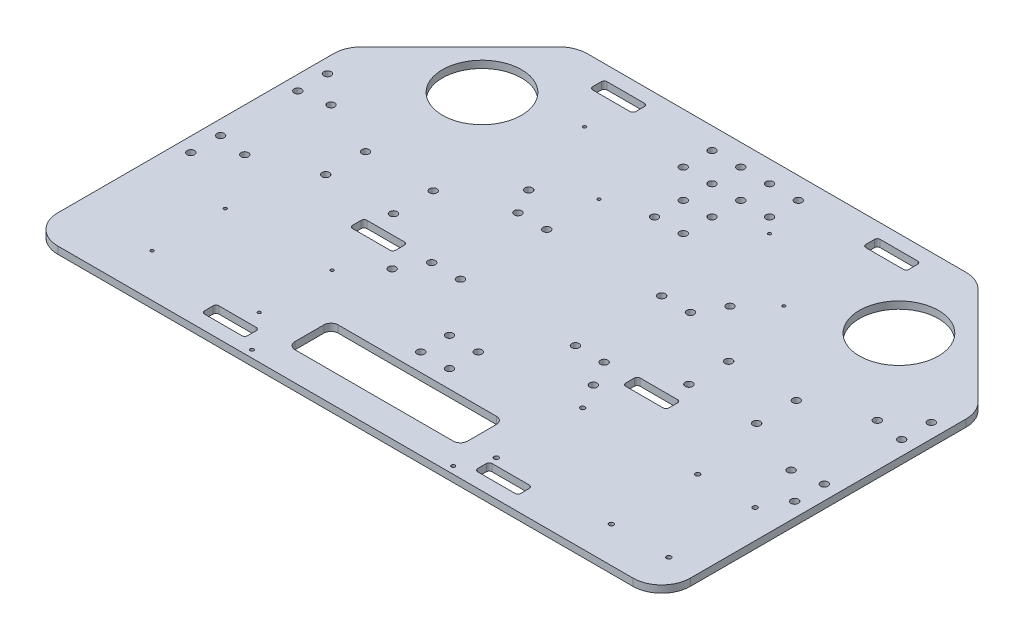
from build123d import *

# Parameters (mm, degrees)
SKETCH1_W          = 558.8
SKETCH1_H          = 381
EXTRUDE1_DEPTH     = 6.35
SKETCH2_R          = 3.2639
CUT_EXTRUDE1_DEPTH = 7.35
CUT_EXTRUDE2_REACH = 8.35
SKETCH4_R          = 3.2639
CUT_EXTRUDE3_DEPTH = 7.35
SKETCH5_R          = 3.2639
CUT_EXTRUDE4_DEPTH = 7.35
SKETCH6_R          = 2.0193
SKETCH6_R_2        = 1.3589
CUT_EXTRUDE5_DEPTH = 7.35
SKETCH7_R          = 3.2639
SKETCH7_R_2        = 1.57988
CUT_EXTRUDE6_DEPTH = 7.35
CUT_EXTRUDE7_DEPTH = 7.35
CHAMFER1_SIZE      = 101.6
FILLET1_R          = 25.4
SKETCH9_R          = 34.925
CUT_EXTRUDE8_DEPTH = 7.35
SKETCH10_R         = 3.2639
CUT_EXTRUDE9_DEPTH = 7.35


with BuildPart() as part:
    # Sketch1 → Extrude1 (new body)
    with BuildSketch(Plane(origin=(0, 0, 0), x_dir=(1, 0, 0), z_dir=(0, 1, 0))):
        Rectangle(SKETCH1_W, SKETCH1_H)
    extrude(amount=EXTRUDE1_DEPTH)

    # Sketch2 → Cut-Extrude1 (cut, through all)
    with BuildSketch(Plane(origin=(0, 6.35, 0), x_dir=(-1, 0, 0), z_dir=(0, 1, 0))):
        with Locations((-130.4671, 17.5641)):
            Circle(SKETCH2_R)
        with Locations((-130.4671, -17.5641)):
            Circle(SKETCH2_R)
        with Locations((130.4671, 17.5641)):
            Circle(SKETCH2_R)
        with Locations((130.4671, -17.5641)):
            Circle(SKETCH2_R)
        with Locations((-190.3095, 17.5641)):
            Circle(SKETCH2_R)
        with Locations((-190.3095, -17.5641)):
            Circle(SKETCH2_R)
        with Locations((190.3095, -17.5641)):
            Circle(SKETCH2_R)
        with Locations((190.3095, 17.5641)):
            Circle(SKETCH2_R)
    extrude(amount=-CUT_EXTRUDE1_DEPTH, mode=Mode.SUBTRACT)

    # Sketch3 → Cut-Extrude2 (cut, up to next)
    with BuildSketch(Plane(origin=(0, 6.35, 0), x_dir=(-1, 0, 0), z_dir=(0, 1, 0)), mode=Mode.PRIVATE) as cut_extrude2_sk1:
        with BuildLine():
            Line((-69.85, 165.1), (69.85, 165.1))
            ThreePointArc((69.85, 165.1), (74.340128061, 163.240128061), (76.2, 158.75))
            Line((76.2, 158.75), (76.2, 133.35))
            ThreePointArc((76.2, 133.35), (74.340128061, 128.859871939), (69.85, 127))
            Line((69.85, 127), (-69.85, 127))
            ThreePointArc((-69.85, 127), (-74.340128061, 128.859871939), (-76.2, 133.35))
            Line((-76.2, 133.35), (-76.2, 158.75))
            ThreePointArc((-76.2, 158.75), (-74.340128061, 163.240128061), (-69.85, 165.1))
        make_face()
    cut_extrude2_tool1 = extrude(cut_extrude2_sk1.sketch, amount=-CUT_EXTRUDE2_REACH, mode=Mode.PRIVATE) & part.part
    add(cut_extrude2_tool1.solids().sort_by_distance((0, 6.35, 146.05))[0], mode=Mode.SUBTRACT)

    # Sketch4 → Cut-Extrude3 (cut, through all)
    with BuildSketch(Plane(origin=(0, 6.35, 0), x_dir=(-1, 0, 0), z_dir=(0, 1, 0))):
        with Locations((-266.6492, 34.13125)):
            Circle(SKETCH4_R)
        with Locations((-266.6492, -34.13125)):
            Circle(SKETCH4_R)
        with Locations((266.6492, -34.13125)):
            Circle(SKETCH4_R)
        with Locations((266.6492, 34.13125)):
            Circle(SKETCH4_R)
    extrude(amount=-CUT_EXTRUDE3_DEPTH, mode=Mode.SUBTRACT)

    # Sketch5 → Cut-Extrude4 (cut, through all)
    with BuildSketch(Plane.XZ):
        with Locations((-266.7, 60.325)):
            Circle(SKETCH5_R)
        with Locations((-88.9, 60.325)):
            Circle(SKETCH5_R)
        with Locations((-88.9, -60.325)):
            Circle(SKETCH5_R)
        with Locations((-266.7, -60.325)):
            Circle(SKETCH5_R)
        with Locations((266.7, -60.325)):
            Circle(SKETCH5_R)
        with Locations((88.9, -60.325)):
            Circle(SKETCH5_R)
        with Locations((88.9, 60.325)):
            Circle(SKETCH5_R)
        with Locations((266.7, 60.325)):
            Circle(SKETCH5_R)
    extrude(amount=-CUT_EXTRUDE4_DEPTH, mode=Mode.SUBTRACT)

    # Sketch6 → Cut-Extrude5 (cut, through all)
    with BuildSketch(Plane(origin=(0, 6.35, 0), x_dir=(-1, 0, 0), z_dir=(0, 1, 0))):
        with Locations((-254, 158.75)):
            Circle(SKETCH6_R)
        with Locations((-203.2, 158.75)):
            Circle(SKETCH6_R)
        with Locations((-101.6, 158.75)):
            Circle(SKETCH6_R)
        with Locations((-254, 82.55)):
            Circle(SKETCH6_R)
        with Locations((-203.2, 82.55)):
            Circle(SKETCH6_R)
        with Locations((-101.6, 82.55)):
            Circle(SKETCH6_R)
        with Locations((114.3, 152.4)):
            Circle(SKETCH6_R_2)
        with Locations((208.788, 152.4)):
            Circle(SKETCH6_R_2)
        with Locations((114.3, 87.9094)):
            Circle(SKETCH6_R_2)
        with Locations((208.788, 87.9094)):
            Circle(SKETCH6_R_2)
        with Locations((-112.522, -84.328)):
            Circle(SKETCH6_R_2)
        with Locations((-50.8, -133.35)):
            Circle(SKETCH6_R_2)
        with Locations((112.522, -133.35)):
            Circle(SKETCH6_R_2)
        with Locations((50.8, -84.328)):
            Circle(SKETCH6_R_2)
    extrude(amount=-CUT_EXTRUDE5_DEPTH, mode=Mode.SUBTRACT)

    # Sketch7 → Cut-Extrude6 (cut, through all)
    with BuildSketch(Plane(origin=(0, 6.35, 0), x_dir=(-1, 0, 0), z_dir=(0, 1, 0))):
        with Locations((-12.7, -171.45)):
            Circle(SKETCH7_R)
        with Locations((12.7, -171.45)):
            Circle(SKETCH7_R)
        with Locations((-12.7, -120.65)):
            Circle(SKETCH7_R)
        with Locations((12.7, -120.65)):
            Circle(SKETCH7_R)
        with Locations((-88.9, 184.15)):
            Circle(SKETCH7_R_2)
        with Locations((88.9, 184.15)):
            Circle(SKETCH7_R_2)
        with Locations((12.7, -146.05)):
            Circle(SKETCH7_R)
        with Locations((-12.7, -146.05)):
            Circle(SKETCH7_R)
        with Locations((38.1, -146.05)):
            Circle(SKETCH7_R)
        with Locations((38.1, -171.45)):
            Circle(SKETCH7_R)
        with Locations((-38.1, -171.45)):
            Circle(SKETCH7_R)
        with Locations((-38.1, -146.05)):
            Circle(SKETCH7_R)
        with Locations((12.7, 85.852)):
            Circle(SKETCH7_R)
        with Locations((-12.7, 85.852)):
            Circle(SKETCH7_R)
        with Locations((12.7, -95.25)):
            Circle(SKETCH7_R)
        with Locations((-12.7, -95.25)):
            Circle(SKETCH7_R)
        with Locations((12.7, 111.252)):
            Circle(SKETCH7_R)
        with Locations((-12.7, 111.252)):
            Circle(SKETCH7_R)
    extrude(amount=-CUT_EXTRUDE6_DEPTH, mode=Mode.SUBTRACT)

    # Sketch8 → Cut-Extrude7 (cut, through all)
    with BuildSketch(Plane.XZ):
        with BuildLine():
            Line((-137.16, 177.8), (-104.14, 177.8))
            ThreePointArc((-104.14, 177.8), (-102.343948776, 177.056051224), (-101.6, 175.26))
            Line((-101.6, 175.26), (-101.6, 167.64))
            ThreePointArc((-101.6, 167.64), (-102.343948776, 165.843948776), (-104.14, 165.1))
            Line((-104.14, 165.1), (-137.16, 165.1))
            ThreePointArc((-137.16, 165.1), (-138.956051224, 165.843948776), (-139.7, 167.64))
            Line((-139.7, 167.64), (-139.7, 175.26))
            ThreePointArc((-139.7, 175.26), (-138.956051224, 177.056051224), (-137.16, 177.8))
        make_face()
        with BuildLine():
            Line((-101.6, -175.26), (-101.6, -167.64))
            ThreePointArc((-101.6, -167.64), (-102.343948776, -165.843948776), (-104.14, -165.1))
            Line((-104.14, -165.1), (-137.16, -165.1))
            ThreePointArc((-137.16, -165.1), (-138.956051224, -165.843948776), (-139.7, -167.64))
            Line((-139.7, -167.64), (-139.7, -175.26))
            ThreePointArc((-139.7, -175.26), (-138.956051224, -177.056051224), (-137.16, -177.8))
            Line((-137.16, -177.8), (-104.14, -177.8))
            ThreePointArc((-104.14, -177.8), (-102.343948776, -177.056051224), (-101.6, -175.26))
        make_face()
        with BuildLine():
            Line((137.16, -177.8), (104.14, -177.8))
            ThreePointArc((104.14, -177.8), (102.343948776, -177.056051224), (101.6, -175.26))
            Line((101.6, -175.26), (101.6, -167.64))
            ThreePointArc((101.6, -167.64), (102.343948776, -165.843948776), (104.14, -165.1))
            Line((104.14, -165.1), (137.16, -165.1))
            ThreePointArc((137.16, -165.1), (138.956051224, -165.843948776), (139.7, -167.64))
            Line((139.7, -167.64), (139.7, -175.26))
            ThreePointArc((139.7, -175.26), (138.956051224, -177.056051224), (137.16, -177.8))
        make_face()
        with BuildLine():
            Line((101.6, 175.26), (101.6, 167.64))
            ThreePointArc((101.6, 167.64), (102.343948776, 165.843948776), (104.14, 165.1))
            Line((104.14, 165.1), (137.16, 165.1))
            ThreePointArc((137.16, 165.1), (138.956051224, 165.843948776), (139.7, 167.64))
            Line((139.7, 167.64), (139.7, 175.26))
            ThreePointArc((139.7, 175.26), (138.956051224, 177.056051224), (137.16, 177.8))
            Line((137.16, 177.8), (104.14, 177.8))
            ThreePointArc((104.14, 177.8), (102.343948776, 177.056051224), (101.6, 175.26))
        make_face()
        with BuildLine():
            Line((101.6, 44.45), (101.6, 36.83))
            ThreePointArc((101.6, 36.83), (102.343948776, 35.033948776), (104.14, 34.29))
            Line((104.14, 34.29), (137.16, 34.29))
            ThreePointArc((137.16, 34.29), (138.956051224, 35.033948776), (139.7, 36.83))
            Line((139.7, 36.83), (139.7, 44.45))
            ThreePointArc((139.7, 44.45), (138.956051224, 46.246051224), (137.16, 46.99))
            Line((137.16, 46.99), (104.14, 46.99))
            ThreePointArc((104.14, 46.99), (102.343948776, 46.246051224), (101.6, 44.45))
        make_face()
        with BuildLine():
            Line((-137.16, 46.99), (-104.14, 46.99))
            ThreePointArc((-104.14, 46.99), (-102.343948776, 46.246051224), (-101.6, 44.45))
            Line((-101.6, 44.45), (-101.6, 36.83))
            ThreePointArc((-101.6, 36.83), (-102.343948776, 35.033948776), (-104.14, 34.29))
            Line((-104.14, 34.29), (-137.16, 34.29))
            ThreePointArc((-137.16, 34.29), (-138.956051224, 35.033948776), (-139.7, 36.83))
            Line((-139.7, 36.83), (-139.7, 44.45))
            ThreePointArc((-139.7, 44.45), (-138.956051224, 46.246051224), (-137.16, 46.99))
        make_face()
    extrude(amount=-CUT_EXTRUDE7_DEPTH, mode=Mode.SUBTRACT)

    # Chamfer1
    chamfer1_edges = [part.edges().sort_by_distance(p)[0] for p in [
        (-279.4, 3.175, -190.5),
        (279.4, 3.175, -190.5),
    ]]
    chamfer(chamfer1_edges, length=CHAMFER1_SIZE)

    # Fillet1
    fillet1_edges = [part.edges().sort_by_distance(p)[0] for p in [
        (-177.8, 3.175, -190.5),
        (177.8, 3.175, -190.5),
        (279.4, 3.175, -88.9),
        (-279.4, 3.175, -88.9),
        (279.4, 3.175, 190.5),
        (-279.4, 3.175, 190.5),
    ]]
    fillet(fillet1_edges, radius=FILLET1_R)

    # Sketch9 → Cut-Extrude8 (cut, through all)
    with BuildSketch(Plane(origin=(0, 6.35, 0), x_dir=(-1, 0, 0), z_dir=(0, 1, 0))):
        with Locations((-184.15, -114.3)):
            Circle(SKETCH9_R)
        with Locations((184.15, -114.3)):
            Circle(SKETCH9_R)
    extrude(amount=-CUT_EXTRUDE8_DEPTH, mode=Mode.SUBTRACT)

    # Sketch10 → Cut-Extrude9 (cut, through all)
    with BuildSketch(Plane.XZ):
        with Locations((-241.3, 38.1)):
            Circle(SKETCH10_R)
        with Locations((-241.3, -38.1)):
            Circle(SKETCH10_R)
        with Locations((241.3, -38.1)):
            Circle(SKETCH10_R)
        with Locations((241.3, 38.1)):
            Circle(SKETCH10_R)
        with Locations((-76.2, 38.1)):
            Circle(SKETCH10_R)
        with Locations((-76.2, -38.1)):
            Circle(SKETCH10_R)
        with Locations((76.2, 38.1)):
            Circle(SKETCH10_R)
        with Locations((76.2, -38.1)):
            Circle(SKETCH10_R)
        with Locations((-50.8, 38.1)):
            Circle(SKETCH10_R)
        with Locations((-50.8, -38.1)):
            Circle(SKETCH10_R)
        with Locations((50.8, -38.1)):
            Circle(SKETCH10_R)
        with Locations((50.8, 38.1)):
            Circle(SKETCH10_R)
    extrude(amount=-CUT_EXTRUDE9_DEPTH, mode=Mode.SUBTRACT)


solid = part.part
